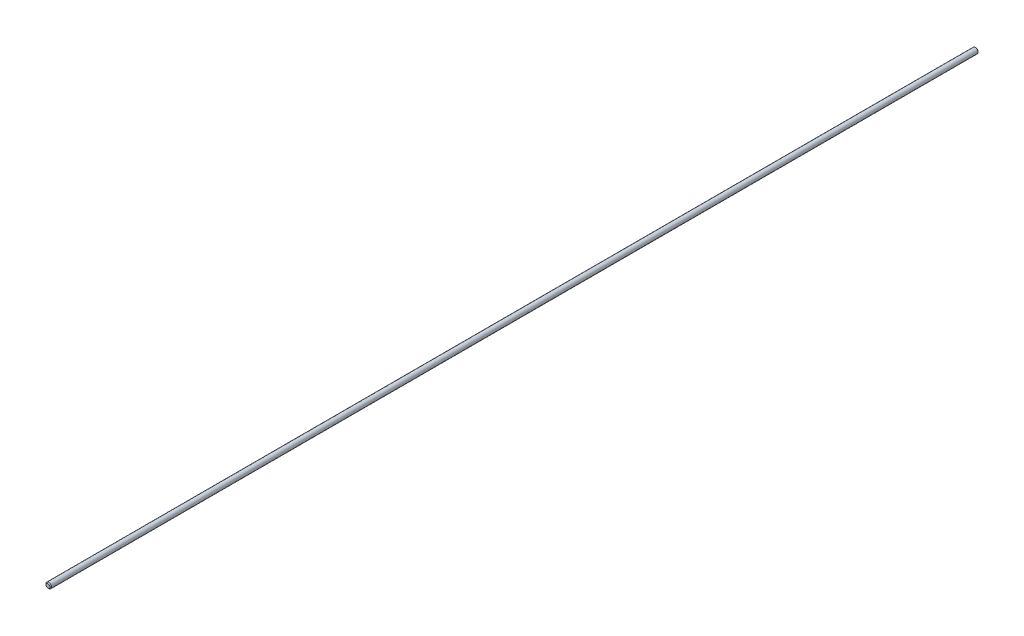
from build123d import *

# Parameters (mm, degrees)
SKETCH2_W     = 532.13
SKETCH2_H     = 1.5875
CHAMFER1_SIZE = 0.47625


with BuildPart() as part:
    # Sketch2 → Revolve1 (revolve)
    with BuildSketch(Plane(origin=(0, 0, 0), x_dir=(0, 0, -1), z_dir=(1, 0, 0))):
        with Locations((0, 0.79375)):
            Rectangle(SKETCH2_W, SKETCH2_H)
    revolve(axis=Axis((0, 0, 266.065), (0, 0, -1)))

    # Chamfer1
    chamfer1_edges = [part.edges().sort_by_distance(p)[0] for p in [
        (0, -1.5875, -266.065),
        (0, -1.5875, 266.065),
    ]]
    chamfer(chamfer1_edges, length=CHAMFER1_SIZE)


solid = part.part
